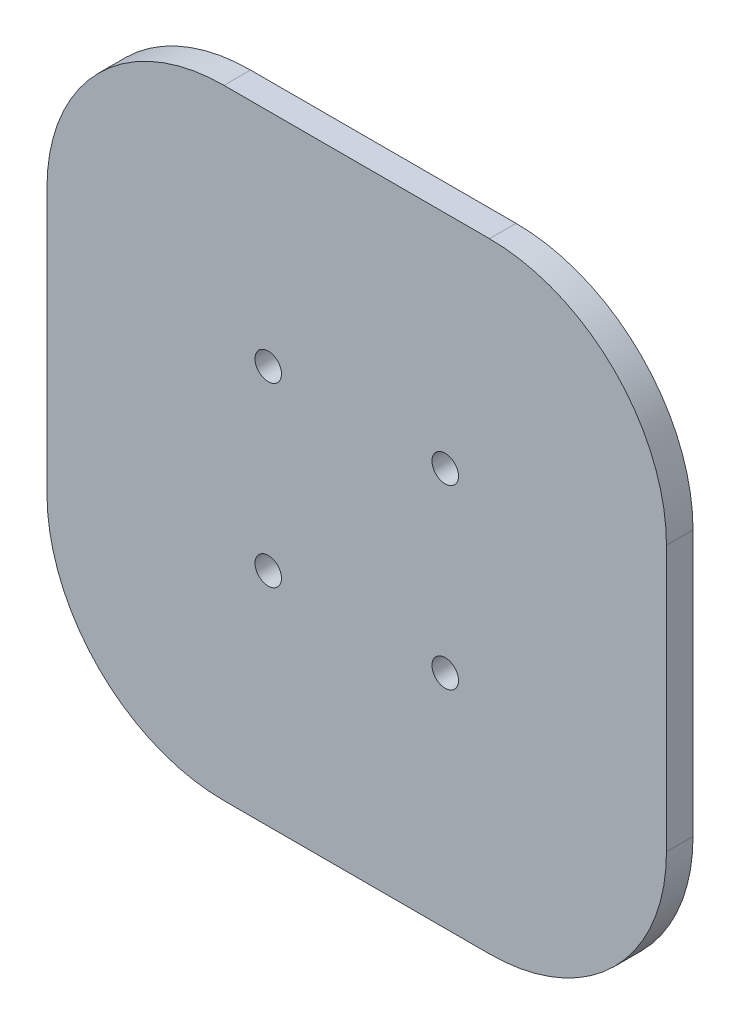
from build123d import *

# Parameters (mm, degrees)
AUFSATZ_LINEAR_AUSTRAGEN1_DEPTH = 3
SCHNITT_LINEAR_AUSTRAGEN1_REACH = 5
SKIZZE2_R                       = 1.5


with BuildPart() as part:
    # Skizze1 → Aufsatz-Linear austragen1 (new body)
    with BuildSketch(Plane.XY):
        with BuildLine():
            Line((-15, -35), (15, -35))
            ThreePointArc((15, -35), (29.142135624, -29.142135624), (35, -15))
            Line((35, -15), (35, 15))
            ThreePointArc((35, 15), (29.142135624, 29.142135624), (15, 35))
            Line((15, 35), (-15, 35))
            ThreePointArc((-15, 35), (-29.142135624, 29.142135624), (-35, 15))
            Line((-35, 15), (-35, -15))
            ThreePointArc((-35, -15), (-29.142135624, -29.142135624), (-15, -35))
        make_face()
    extrude(amount=AUFSATZ_LINEAR_AUSTRAGEN1_DEPTH)

    # Skizze2 → Schnitt-Linear austragen1 (cut, up to next)
    with BuildSketch(Plane.XY.offset(3), mode=Mode.PRIVATE) as schnitt_linear_austragen1_sk1:
        with Locations((-10, 10)):
            Circle(SKIZZE2_R)
    schnitt_linear_austragen1_tool1 = extrude(schnitt_linear_austragen1_sk1.sketch, amount=-SCHNITT_LINEAR_AUSTRAGEN1_REACH, mode=Mode.PRIVATE) & part.part
    add(schnitt_linear_austragen1_tool1.solids().sort_by_distance((-10, 10, 3))[0], mode=Mode.SUBTRACT)
    # Skizze2 → Schnitt-Linear austragen1 (cut, up to next)
    with BuildSketch(Plane.XY.offset(3), mode=Mode.PRIVATE) as schnitt_linear_austragen1_sk2:
        with Locations((10, 10)):
            Circle(SKIZZE2_R)
    schnitt_linear_austragen1_tool2 = extrude(schnitt_linear_austragen1_sk2.sketch, amount=-SCHNITT_LINEAR_AUSTRAGEN1_REACH, mode=Mode.PRIVATE) & part.part
    add(schnitt_linear_austragen1_tool2.solids().sort_by_distance((10, 10, 3))[0], mode=Mode.SUBTRACT)
    # Skizze2 → Schnitt-Linear austragen1 (cut, up to next)
    with BuildSketch(Plane.XY.offset(3), mode=Mode.PRIVATE) as schnitt_linear_austragen1_sk3:
        with Locations((10, -10)):
            Circle(SKIZZE2_R)
    schnitt_linear_austragen1_tool3 = extrude(schnitt_linear_austragen1_sk3.sketch, amount=-SCHNITT_LINEAR_AUSTRAGEN1_REACH, mode=Mode.PRIVATE) & part.part
    add(schnitt_linear_austragen1_tool3.solids().sort_by_distance((10, -10, 3))[0], mode=Mode.SUBTRACT)
    # Skizze2 → Schnitt-Linear austragen1 (cut, up to next)
    with BuildSketch(Plane.XY.offset(3), mode=Mode.PRIVATE) as schnitt_linear_austragen1_sk4:
        with Locations((-10, -10)):
            Circle(SKIZZE2_R)
    schnitt_linear_austragen1_tool4 = extrude(schnitt_linear_austragen1_sk4.sketch, amount=-SCHNITT_LINEAR_AUSTRAGEN1_REACH, mode=Mode.PRIVATE) & part.part
    add(schnitt_linear_austragen1_tool4.solids().sort_by_distance((-10, -10, 3))[0], mode=Mode.SUBTRACT)


solid = part.part
